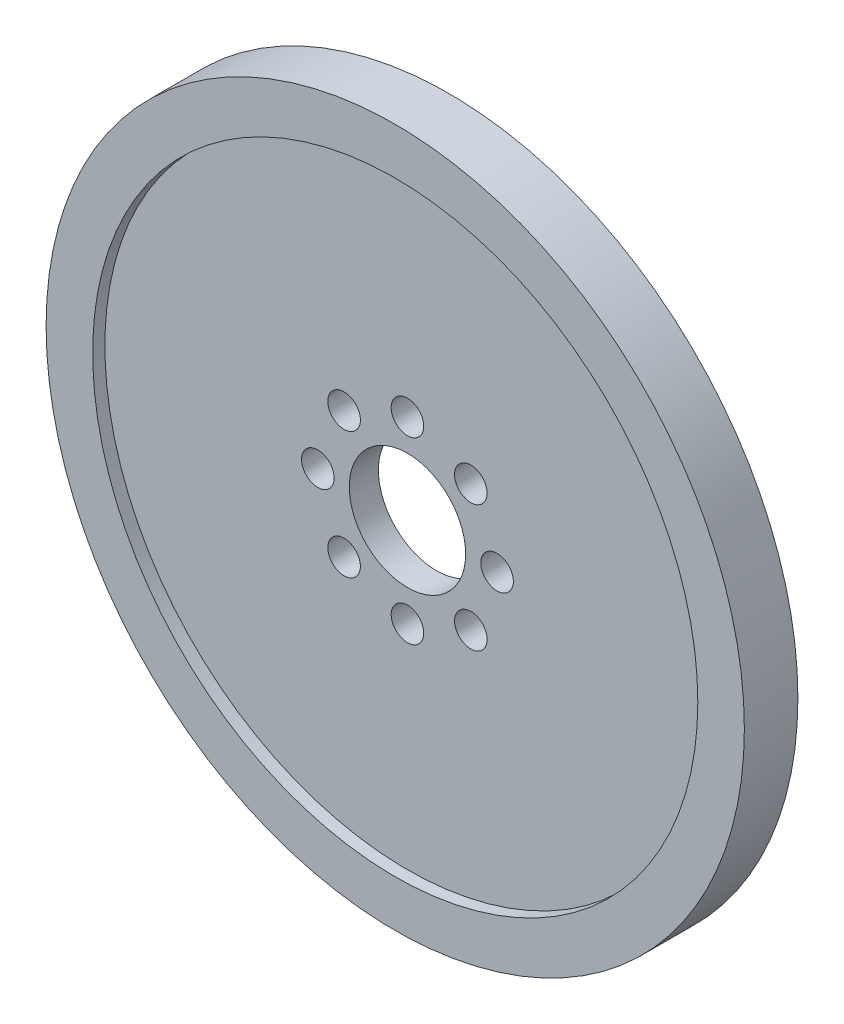
from build123d import *

# Parameters (mm, degrees)
SKETCH1_R           = 38.1
SKETCH1_R_2         = 33.02
BOSS_EXTRUDE1_DEPTH = 2.921
SKETCH3_R           = 33.02
SKETCH3_R_2         = 6.35
SKETCH3_R_3         = 1.778
BOSS_EXTRUDE2_DEPTH = 1.5875


with BuildPart() as part:
    # Sketch1 → Boss-Extrude1 (new body, symmetric)
    with BuildSketch(Plane.XY):
        Circle(SKETCH1_R)
        Circle(SKETCH1_R_2, mode=Mode.SUBTRACT)
    extrude(amount=BOSS_EXTRUDE1_DEPTH, both=True)

    # Sketch3 → Boss-Extrude2 (add, symmetric)
    with BuildSketch(Plane.XY):
        Circle(SKETCH3_R)
        Circle(SKETCH3_R_2, mode=Mode.SUBTRACT)
        with Locations((0, 9.779)):
            Circle(SKETCH3_R_3, mode=Mode.SUBTRACT)
        with Locations((6.914797213, 6.914797213)):
            Circle(SKETCH3_R_3, mode=Mode.SUBTRACT)
        with Locations((9.779, 0)):
            Circle(SKETCH3_R_3, mode=Mode.SUBTRACT)
        with Locations((6.914797213, -6.914797213)):
            Circle(SKETCH3_R_3, mode=Mode.SUBTRACT)
        with Locations((0, -9.779)):
            Circle(SKETCH3_R_3, mode=Mode.SUBTRACT)
        with Locations((-6.914797213, -6.914797213)):
            Circle(SKETCH3_R_3, mode=Mode.SUBTRACT)
        with Locations((-9.779, 0)):
            Circle(SKETCH3_R_3, mode=Mode.SUBTRACT)
        with Locations((-6.914797213, 6.914797213)):
            Circle(SKETCH3_R_3, mode=Mode.SUBTRACT)
    extrude(amount=BOSS_EXTRUDE2_DEPTH, both=True)


solid = part.part
